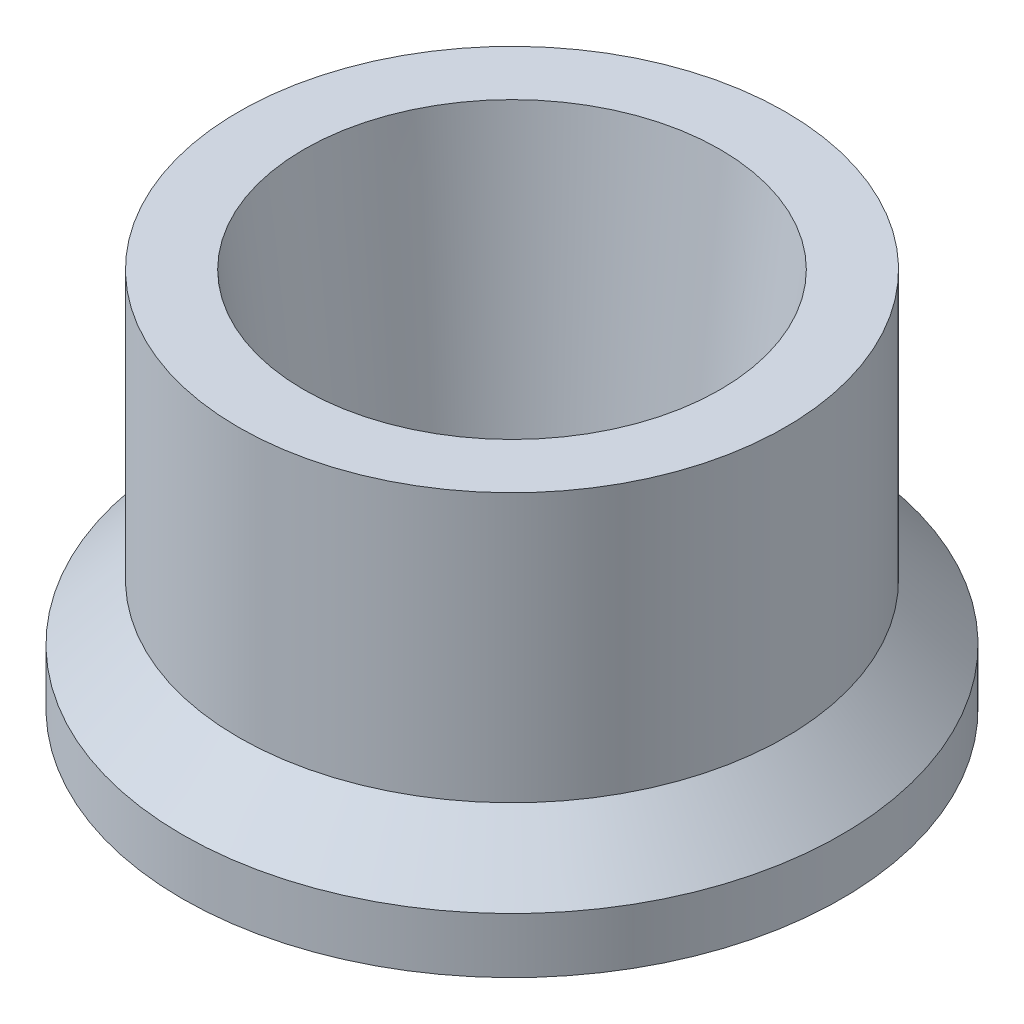
from build123d import *


with BuildPart() as part:
    # Sketch1 → Revolve1 (revolve)
    with BuildSketch(Plane.XY):
        Polygon((3.048, 0), (3.81, 6.9596), (5.0038, 6.9596), (5.0038, 2.0447), (6.0325, 1.016), (6.0325, 0), align=None)
    revolve(axis=Axis((0, 0, 0), (0, 1, 0)))


solid = part.part
